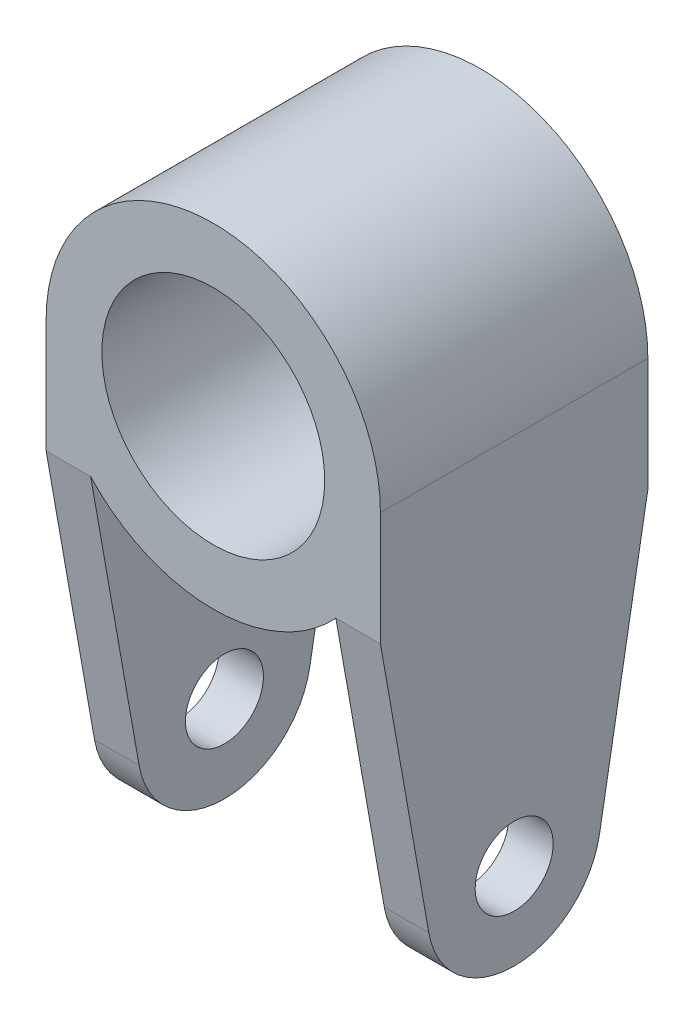
from build123d import *

# Parameters (mm, degrees)
SKETCH2_R           = 10
BOSS_EXTRUDE1_DEPTH = 24
CUT_EXTRUDE1_REACH  = 32
SKETCH3_R           = 3.5
CUT_EXTRUDE2_REACH  = 32
SKETCH4_R           = 3.5


with BuildPart() as part:
    # Sketch2 → Boss-Extrude1 (new body)
    with BuildSketch(Plane.XY):
        with BuildLine():
            Line((-15, 0), (-15, -15))
            Line((-15, -15), (-15, -42))
            Line((-15, -42), (-11, -42))
            Line((-11, -42), (-11, -10.198039027))
            ThreePointArc((-11, -10.198039027), (0, -15), (11, -10.198039027))
            Line((11, -10.198039027), (11, -42))
            Line((11, -42), (15, -42))
            Line((15, -42), (15, -22))
            Line((15, -22), (15, 0))
            ThreePointArc((15, 0), (0, 15), (-15, 0))
        make_face()
        Circle(SKETCH2_R, mode=Mode.SUBTRACT)
    extrude(amount=BOSS_EXTRUDE1_DEPTH)

    # Sketch3 → Cut-Extrude1 (cut, up to next)
    with BuildSketch(Plane.ZY.offset(15), mode=Mode.PRIVATE) as cut_extrude1_sk1:
        with Locations((12, -33.467780556)):
            Circle(SKETCH3_R)
    cut_extrude1_tool1 = extrude(cut_extrude1_sk1.sketch, amount=-CUT_EXTRUDE1_REACH, mode=Mode.PRIVATE) & part.part
    add(cut_extrude1_tool1.solids().sort_by_distance((-15, -33.467781, 12))[0], mode=Mode.SUBTRACT)
    # Sketch3 → Cut-Extrude1 (cut, up to next)
    with BuildSketch(Plane.ZY.offset(15), mode=Mode.PRIVATE) as cut_extrude1_sk2:
        with BuildLine():
            Line((0, -10.198039027), (4.341204442, -34.818232852))
            ThreePointArc((4.341204442, -34.818232852), (12, -41.244725381), (19.658795558, -34.818232852))
            Line((19.658795558, -34.818232852), (24, -10.198039027))
            Line((24, -10.198039027), (24, -42))
            Line((24, -42), (0, -42))
            Line((0, -42), (0, -10.198039027))
        make_face()
    cut_extrude1_tool2 = extrude(cut_extrude1_sk2.sketch, amount=-CUT_EXTRUDE1_REACH, mode=Mode.PRIVATE) & part.part
    add(cut_extrude1_tool2.solids().sort_by_distance((-15, -22.57732, 1.778238))[0], mode=Mode.SUBTRACT)

    # Sketch4 → Cut-Extrude2 (cut, up to next)
    with BuildSketch(Plane(origin=(15, 0, 0), x_dir=(0, 0, -1), z_dir=(1, 0, 0)), mode=Mode.PRIVATE) as cut_extrude2_sk1:
        with Locations((-12, -33.467780556)):
            Circle(SKETCH4_R)
    cut_extrude2_tool1 = extrude(cut_extrude2_sk1.sketch, amount=-CUT_EXTRUDE2_REACH, mode=Mode.PRIVATE) & part.part
    add(cut_extrude2_tool1.solids().sort_by_distance((15, -33.467781, 12))[0], mode=Mode.SUBTRACT)
    # Sketch4 → Cut-Extrude2 (cut, up to next)
    with BuildSketch(Plane(origin=(15, 0, 0), x_dir=(0, 0, -1), z_dir=(1, 0, 0)), mode=Mode.PRIVATE) as cut_extrude2_sk2:
        with BuildLine():
            Line((0, -10.198039027), (-4.341204442, -34.818232852))
            ThreePointArc((-4.341204442, -34.818232852), (-12, -41.244725381), (-19.658795558, -34.818232852))
            Line((-19.658795558, -34.818232852), (-24, -10.198039027))
            Line((-24, -10.198039027), (-24, -42))
            Line((-24, -42), (0, -42))
            Line((0, -42), (0, -10.198039027))
        make_face()
    cut_extrude2_tool2 = extrude(cut_extrude2_sk2.sketch, amount=-CUT_EXTRUDE2_REACH, mode=Mode.PRIVATE) & part.part
    add(cut_extrude2_tool2.solids().sort_by_distance((15, -22.57732, 1.778238))[0], mode=Mode.SUBTRACT)


solid = part.part
